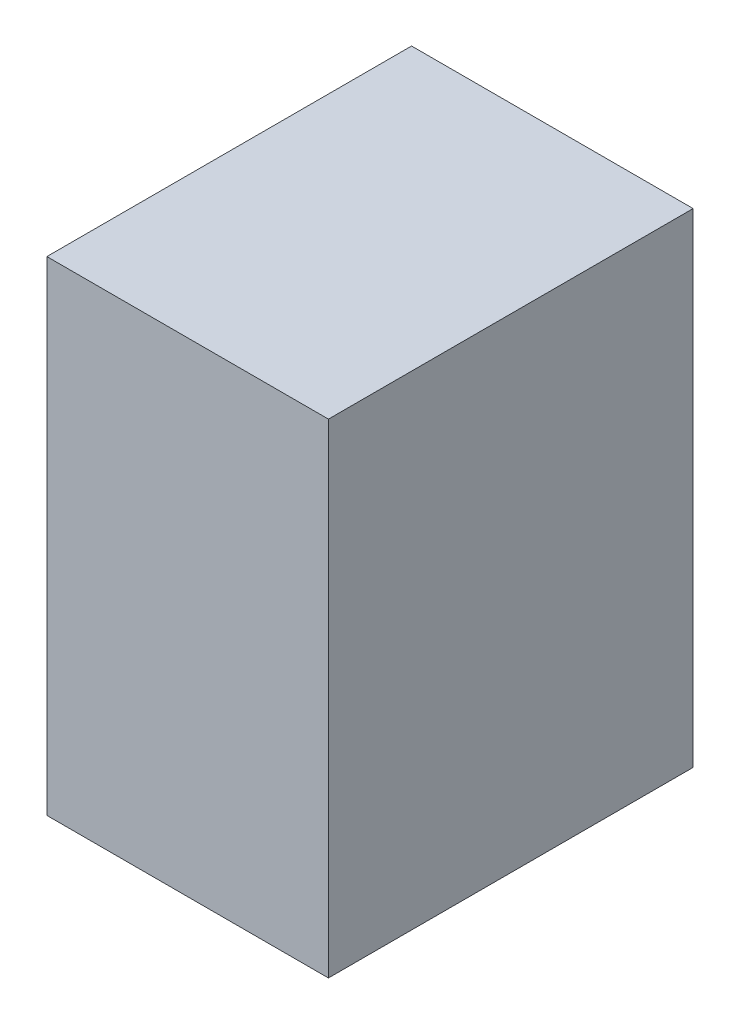
from build123d import *

# Parameters (mm, degrees)
SKETCH_1_W      = 210
SKETCH_1_H      = 272
EXTRUDE_1_DEPTH = 361


with BuildPart() as part:
    # Эскиз1 → Бобышка-Вытянуть1 (new body)
    with BuildSketch(Plane(origin=(0, 0, 0), x_dir=(1, 0, 0), z_dir=(0, 1, 0))):
        with Locations((-1171.357087425, 2454.625162548)):
            Rectangle(SKETCH_1_W, SKETCH_1_H)
    extrude(amount=EXTRUDE_1_DEPTH)


solid = part.part
